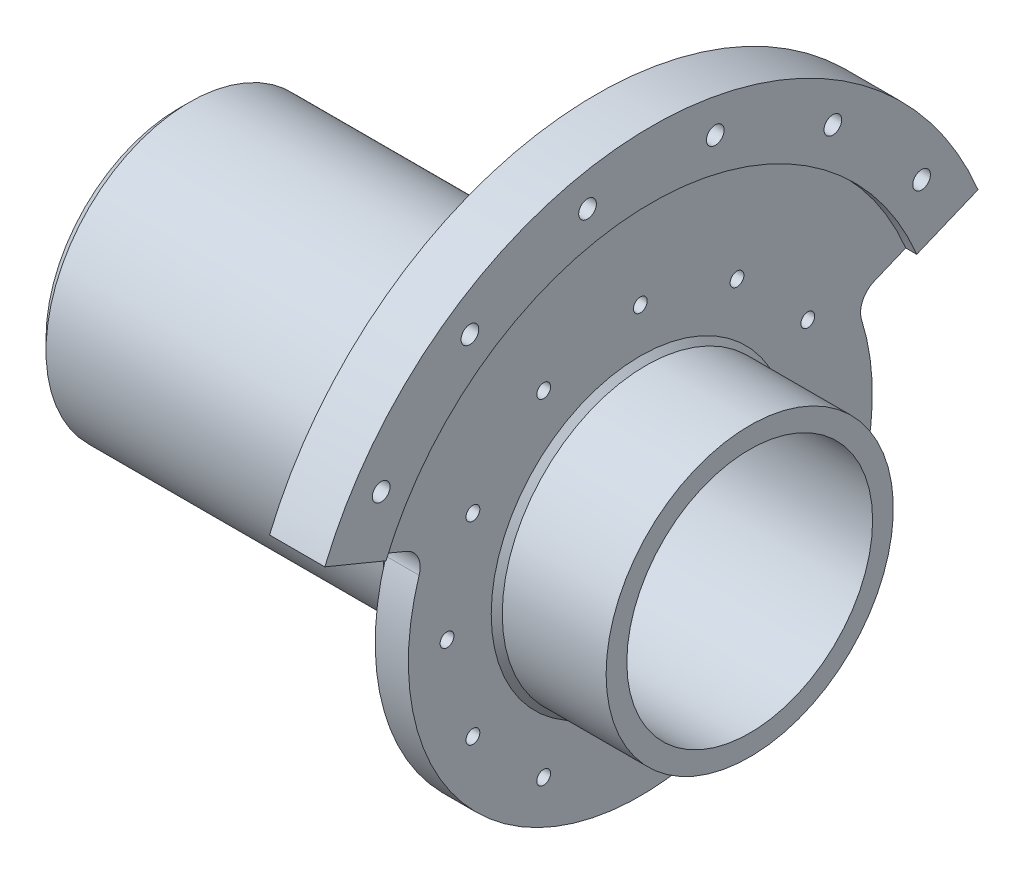
from build123d import *

# Parameters (mm, degrees)
SKETCH1_W                                    = 51.7
SKETCH1_H                                    = 1.875
SKETCH2_W                                    = 3
SKETCH2_H                                    = 3.625
CHAMFER1_SIZE                                = 1
M2_CLEARANCE_HOLE1_D                         = 2.4
M2_CLEARANCE_HOLE1_DEPTH                     = 11.5
CIRPATTERN1_COUNT                            = 6
SKETCH6_W                                    = 3
SKETCH6_H                                    = 19
REVOLVE3_ANGLE                               = 135
SKETCH9_W                                    = 3
SKETCH9_H                                    = 8
CHAMFER2_SIZE                                = 0.5
SKETCH11_W                                   = 5
SKETCH11_H                                   = 6
REVOLVE5_ANGLE                               = 135
CHAMFER4_SIZE                                = 1
TAP_DRILL_FOR_M1_6_TAP1_D                    = 1.25
TAP_DRILL_FOR_M1_6_TAP1_DEPTH                = 11.5
CIRPATTERN2_COUNT                            = 12
FILLET1_R                                    = 2
SKETCH17_W                                   = 2.5
SKETCH17_H                                   = 1.95
ESQUISSE2_W                                  = 1
ESQUISSE2_H                                  = 6
R_VOLUTION4_ANGLE                            = 135
SKETCH13_W                                   = 0.8
SKETCH13_H                                   = 41.8
TROU_POUR_TARAUDAGE_POUR_TROU_TARAUD_2_COUNT = 2
TROU_POUR_TARAUDAGE_POUR_TROU_TARAUD_2_PITCH = 11.563340196
TROU_POUR_TARAUDAGE_POUR_TROU_TARAUD_3_COUNT = 2
TROU_POUR_TARAUDAGE_POUR_TROU_TARAUD_3_PITCH = 11.563340196
TROU_POUR_TARAUDAGE_POUR_TROU_TARAUD_4_COUNT = 2
TROU_POUR_TARAUDAGE_POUR_TROU_TARAUD_4_PITCH = 22.662405452
TROU_POUR_TARAUDAGE_POUR_TROU_TARAUD_5_COUNT = 2
TROU_POUR_TARAUDAGE_POUR_TROU_TARAUD_5_PITCH = 32.851561742
TROU_POUR_TARAUDAGE_POUR_TROU_TARAUD_6_COUNT = 2
TROU_POUR_TARAUDAGE_POUR_TROU_TARAUD_6_PITCH = 41.72170842


with BuildPart() as part:
    # Sketch1 → Revolve1 (revolve)
    with BuildSketch(Plane.XY):
        with Locations((-14.45, 12.0625)):
            Rectangle(SKETCH1_W, SKETCH1_H)
    revolve(axis=Axis((0, 0, 0), (1, 0, 0)))

    # Sketch2 → Revolve2 (revolve)
    with BuildSketch(Plane.XY):
        with Locations((-38.8, 9.3125)):
            Rectangle(SKETCH2_W, SKETCH2_H)
    revolve(axis=Axis((-40.3, 0, 0), (1, 0, 0)))

    # Chamfer1
    chamfer1_edges = [part.edges().sort_by_distance(p)[0] for p in [
        (-40.3, -13, 0),
    ]]
    chamfer(chamfer1_edges, length=CHAMFER1_SIZE)

    # M2 Clearance Hole1
    with Locations(Plane.ZY.offset(40.3)):
        with Locations((0, 9.5)):
            m2_clearance_hole1 = Hole(M2_CLEARANCE_HOLE1_D / 2, depth=M2_CLEARANCE_HOLE1_DEPTH)

    # CirPattern1: M2 Clearance Hole1 ×6 about axis
    cirpattern1_axis = Axis((0, 0, 0), (1, 0, 0))
    for i in range(1, CIRPATTERN1_COUNT):
        add(m2_clearance_hole1.rotate(cirpattern1_axis, i * 360 / CIRPATTERN1_COUNT), mode=Mode.SUBTRACT)

    # Sketch6 → Revolve3 (revolve, symmetric)
    with BuildSketch(Plane.XY) as revolve3_sk:
        with Locations((0, 22.5)):
            Rectangle(SKETCH6_W, SKETCH6_H)
    revolve(axis=Axis((0, 0, 0), (1, 0, 0)), revolution_arc=REVOLVE3_ANGLE / 2)
    revolve(revolve3_sk.sketch, axis=Axis((0, 0, 0), (-1, 0, 0)), revolution_arc=REVOLVE3_ANGLE / 2)

    # Sketch9 → Revolve4 (revolve)
    with BuildSketch(Plane.XY):
        with Locations((0, 17)):
            Rectangle(SKETCH9_W, SKETCH9_H)
    revolve(axis=Axis((0, 0, 0), (1, 0, 0)))

    # Chamfer2
    chamfer2_edges = [part.edges().sort_by_distance(p)[0] for p in [
        (-1.5, -13, 0),
        (1.5, -13, 0),
    ]]
    chamfer(chamfer2_edges, length=CHAMFER2_SIZE)

    # Sketch11 → Revolve5 (revolve, symmetric)
    with BuildSketch(Plane.XY) as revolve5_sk:
        with Locations((-1, 29)):
            Rectangle(SKETCH11_W, SKETCH11_H)
    revolve(axis=Axis((0, 0, 0), (1, 0, 0)), revolution_arc=REVOLVE5_ANGLE / 2)
    revolve(revolve5_sk.sketch, axis=Axis((0, 0, 0), (-1, 0, 0)), revolution_arc=REVOLVE5_ANGLE / 2)

    # Chamfer4
    chamfer4_edges = [part.edges().sort_by_distance(p)[0] for p in [
        (-3.5, 32, 0),
    ]]
    chamfer(chamfer4_edges, length=CHAMFER4_SIZE)

    # Tap Drill for M1.6 Tap1
    with Locations(Plane.ZY.offset(1.5)):
        with Locations((0, 17.5)):
            tap_drill_for_m1_6_tap1 = Hole(TAP_DRILL_FOR_M1_6_TAP1_D / 2, depth=TAP_DRILL_FOR_M1_6_TAP1_DEPTH)

    # CirPattern2: Tap Drill for M1.6 Tap1 ×12 about axis
    cirpattern2_axis = Axis((0, 0, 0), (1, 0, 0))
    for i in range(1, CIRPATTERN2_COUNT):
        add(tap_drill_for_m1_6_tap1.rotate(cirpattern2_axis, i * 360 / CIRPATTERN2_COUNT), mode=Mode.SUBTRACT)

    # Fillet1
    fillet1_edges = [part.edges().sort_by_distance(p)[0] for p in [
        (0, 8.03635208, -19.401470183),
        (0, 8.03635208, 19.401470183),
    ]]
    fillet(fillet1_edges, radius=FILLET1_R)

    # Sketch17 → Revolve6 (revolve)
    with BuildSketch(Plane.XY):
        with Locations((-5.55, 13.975)):
            Rectangle(SKETCH17_W, SKETCH17_H)
    revolve(axis=Axis((0, 0, 0), (-1, 0, 0)))

    # Esquisse1 → Enlèvement de matière-Révolution1 (revolve, cut)
    with BuildSketch(Plane(origin=(0, 0, 0), x_dir=(1, 0, 0), z_dir=(0, -0.923879533, 0.382683432))):
        Polygon((-3.5, 31), (-2.5, 32), (-2.5, 26), (-3.5, 26), align=None)
    revolve(axis=Axis((-40.3, 0, 0), (1, 0, 0)), mode=Mode.SUBTRACT)

    # Esquisse2 → Révolution4 (revolve)
    with BuildSketch(Plane(origin=(0, 0, 0), x_dir=(1, 0, 0), z_dir=(0, -0.923879533, 0.382683432))):
        with Locations((2, 29)):
            Rectangle(ESQUISSE2_W, ESQUISSE2_H)
    revolve(axis=Axis((11.4, 0, 0), (-1, 0, 0)), revolution_arc=R_VOLUTION4_ANGLE)

    # Sketch13 → Trou pour taraudage pour trou taraudé M21 (revolve, cut)
    with BuildSketch(Plane(origin=(1.5, 23.89965947, -16.425780871), x_dir=(0, 0, -1), z_dir=(0, 1, 0))):
        with Locations((0.4, 19.9)):
            Rectangle(SKETCH13_W, SKETCH13_H)
    trou_pour_taraudage_pour_trou_taraud_m2 = revolve(axis=Axis((8.85, 23.89965947, -16.425780871), (-1, 0, 0)), mode=Mode.SUBTRACT)

    # Trou pour taraudage pour trou taraud 2: Trou pour taraudage pour trou taraudé M21 ×2
    with Locations(*[Vector(0, -0.7193398, -0.69465837) * (i * TROU_POUR_TARAUDAGE_POUR_TROU_TARAUD_2_PITCH) for i in range(1, TROU_POUR_TARAUDAGE_POUR_TROU_TARAUD_2_COUNT)]):
        add(trou_pour_taraudage_pour_trou_taraud_m2, mode=Mode.SUBTRACT)

    # Trou pour taraudage pour trou taraud 3: Trou pour taraudage pour trou taraudé M21 ×2
    with Locations(*[Vector(0, 0.390731128, 0.920504853) * (i * TROU_POUR_TARAUDAGE_POUR_TROU_TARAUD_3_PITCH) for i in range(1, TROU_POUR_TARAUDAGE_POUR_TROU_TARAUD_3_COUNT)]):
        add(trou_pour_taraudage_pour_trou_taraud_m2, mode=Mode.SUBTRACT)

    # Trou pour taraudage pour trou taraud 4: Trou pour taraudage pour trou taraudé M21 ×2
    with Locations(*[Vector(0, 0.199367934, 0.979924705) * (i * TROU_POUR_TARAUDAGE_POUR_TROU_TARAUD_4_PITCH) for i in range(1, TROU_POUR_TARAUDAGE_POUR_TROU_TARAUD_4_COUNT)]):
        add(trou_pour_taraudage_pour_trou_taraud_m2, mode=Mode.SUBTRACT)

    # Trou pour taraudage pour trou taraud 5: Trou pour taraudage pour trou taraudé M21 ×2
    with Locations(*[(0, 0, i * TROU_POUR_TARAUDAGE_POUR_TROU_TARAUD_5_PITCH) for i in range(1, TROU_POUR_TARAUDAGE_POUR_TROU_TARAUD_5_COUNT)]):
        add(trou_pour_taraudage_pour_trou_taraud_m2, mode=Mode.SUBTRACT)

    # Trou pour taraudage pour trou taraud 6: Trou pour taraudage pour trou taraudé M21 ×2
    with Locations(*[Vector(0, -0.199367934, 0.979924705) * (i * TROU_POUR_TARAUDAGE_POUR_TROU_TARAUD_6_PITCH) for i in range(1, TROU_POUR_TARAUDAGE_POUR_TROU_TARAUD_6_COUNT)]):
        add(trou_pour_taraudage_pour_trou_taraud_m2, mode=Mode.SUBTRACT)


solid = part.part
